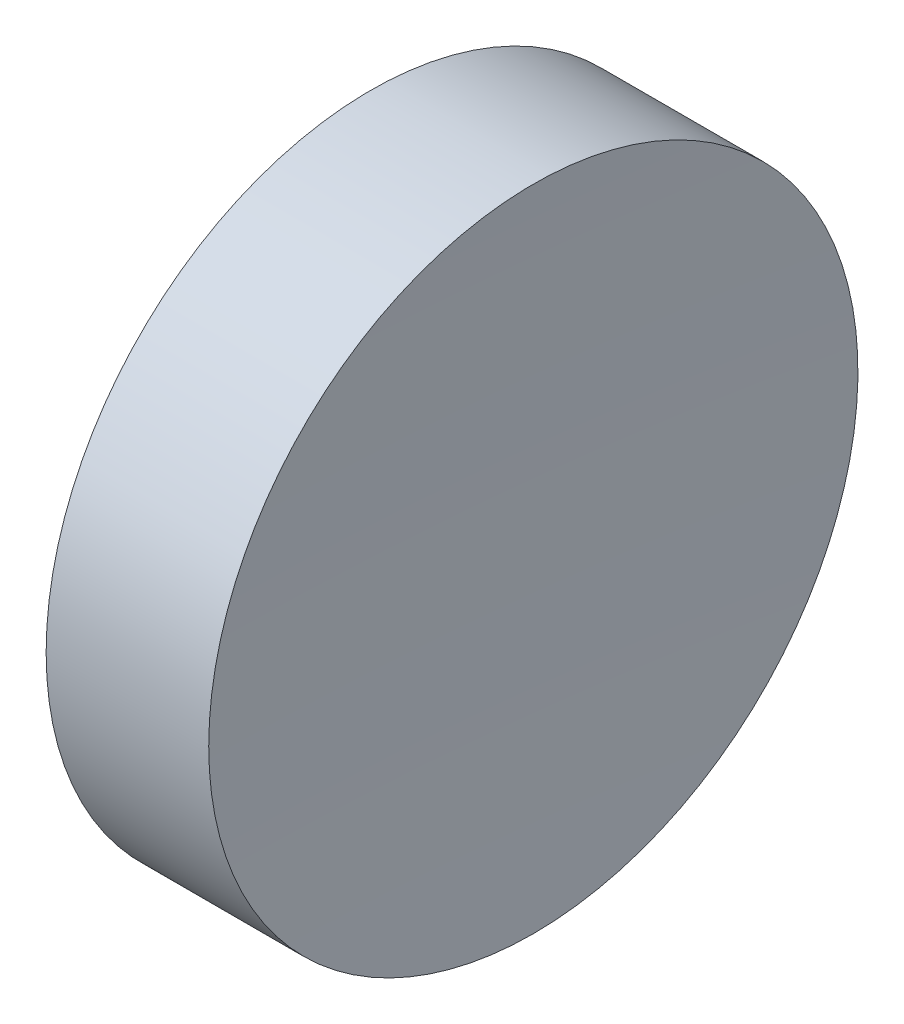
from build123d import *


with BuildPart() as part:
    # 草图1 → 旋转1 (revolve)
    with BuildSketch(Plane.XY, mode=Mode.PRIVATE) as revolve_1_sk:
        with BuildLine():
            Line((57.546327767, 34.689010562), (57.546327767, 40.939010562))
            Line((57.546327767, 40.939010562), (60.676592493, 40.939010562))
            ThreePointArc((60.676592493, 40.939010562), (60.578897356, 37.814689246), (60.546327596, 34.689010562))
            Line((60.546327596, 34.689010562), (57.546327767, 34.689010562))
        make_face()
    revolve(revolve_1_sk.sketch.rotate(Axis((54.492571501, 34.689010562, 0), (1, 0, 0)), 180), axis=Axis((54.492571501, 34.689010562, 0), (1, 0, 0)))  # turned: the seam where the file's is


solid = part.part
